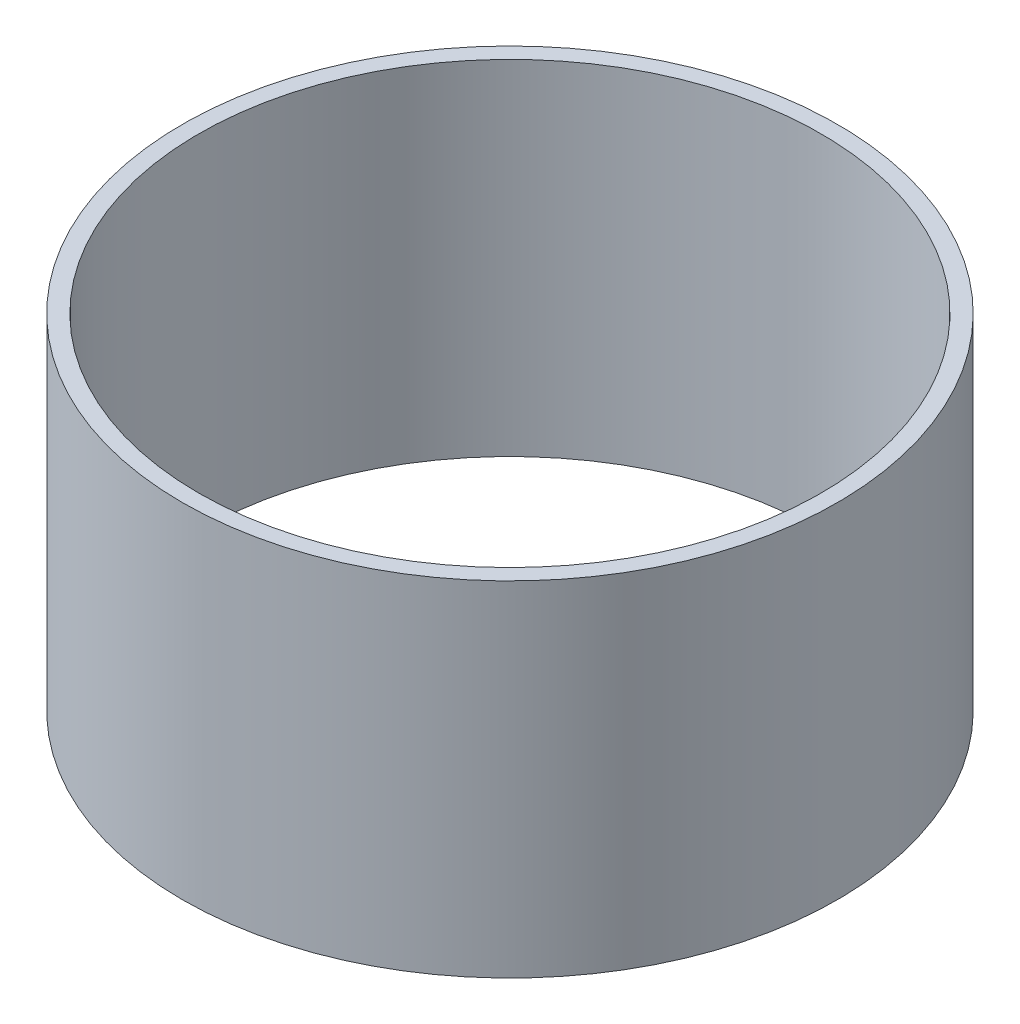
from build123d import *

# Parameters (mm, degrees)
SKETCH_1_R      = 40
SKETCH_1_R_2    = 38
EXTRUDE_1_DEPTH = 42


with BuildPart() as part:
    # 草图1 → 凸台-拉伸1 (new body)
    with BuildSketch(Plane(origin=(0, 0, 0), x_dir=(1, 0, 0), z_dir=(0, 1, 0))):
        Circle(SKETCH_1_R)
        Circle(SKETCH_1_R_2, mode=Mode.SUBTRACT)
    extrude(amount=EXTRUDE_1_DEPTH)


solid = part.part
